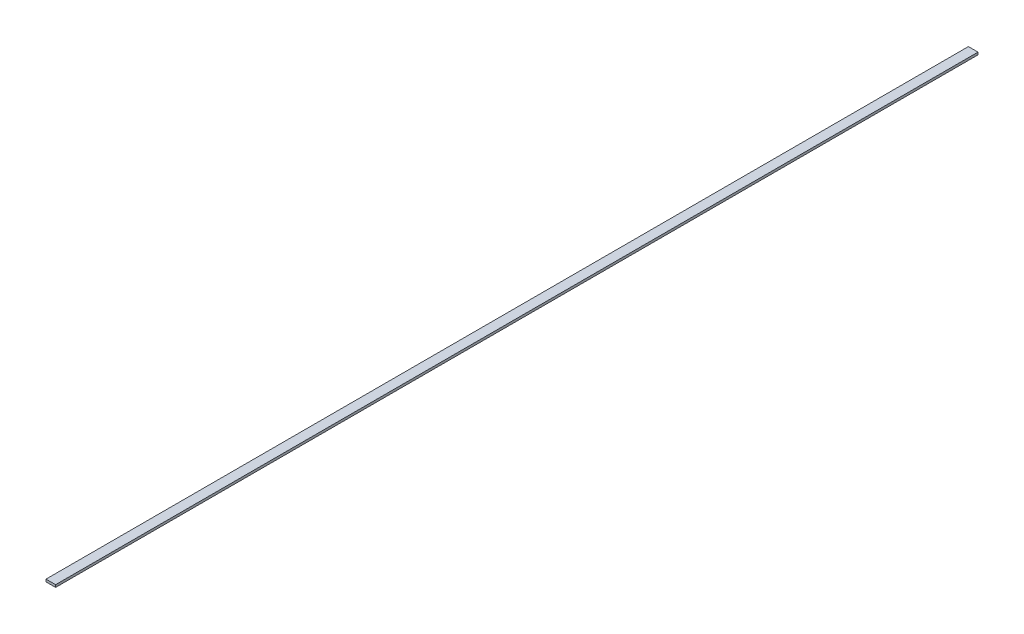
from build123d import *

# Parameters (mm, degrees)
SKETCH1_W           = 12.7
SKETCH1_H           = 1219.2
BOSS_EXTRUDE1_DEPTH = 1.5875


with BuildPart() as part:
    # Sketch1 → Boss-Extrude1 (new body, symmetric)
    with BuildSketch(Plane(origin=(0, 0, 0), x_dir=(1, 0, 0), z_dir=(0, 1, 0))):
        Rectangle(SKETCH1_W, SKETCH1_H)
    extrude(amount=BOSS_EXTRUDE1_DEPTH, both=True)


solid = part.part
